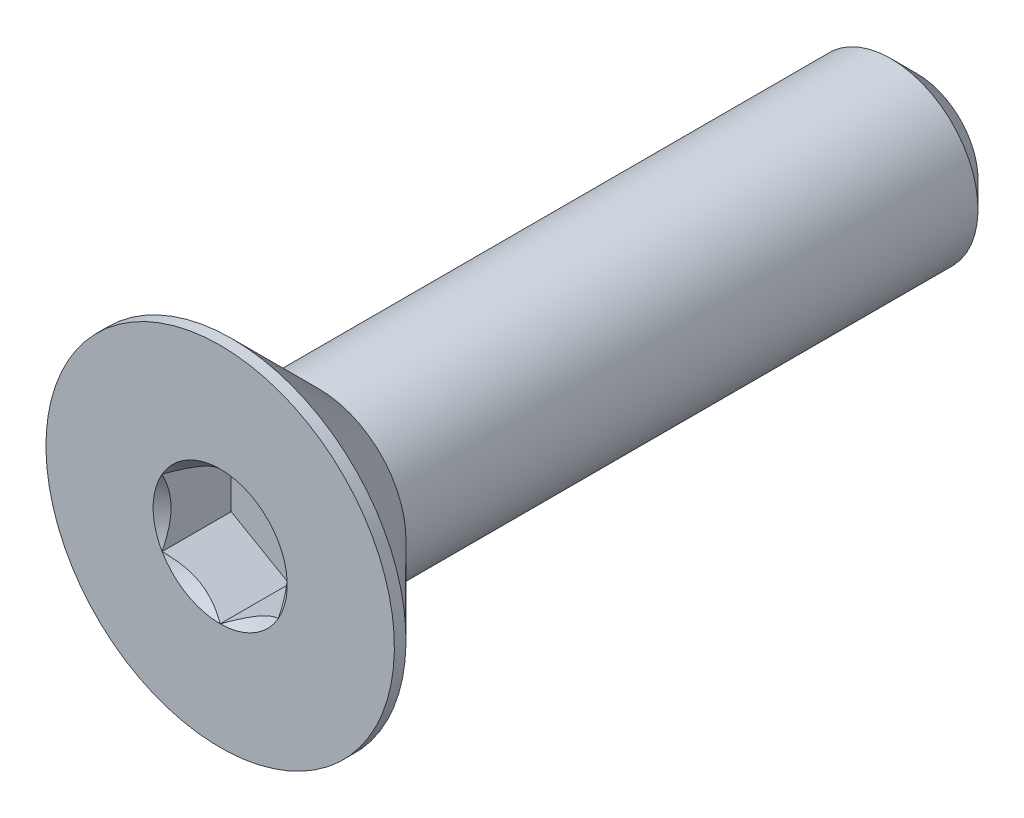
from build123d import *

# Parameters (mm, degrees)
SKETCH3_W          = 12
SKETCH3_H          = 1.5
CHAMFER1_SIZE      = 0.45
CUT_EXTRUDE1_DEPTH = 1.19


with BuildPart() as part:
    # Sketch3 → Revolve1 (revolve)
    with BuildSketch(Plane(origin=(0, 0, 0), x_dir=(0, 0, -1), z_dir=(1, 0, 0))):
        with Locations((0, 0.75)):
            Rectangle(SKETCH3_W, SKETCH3_H)
    revolve(axis=Axis((0, 0, -6), (0, 0, 1)))

    # Chamfer1
    chamfer1_edges = [part.edges().sort_by_distance(p)[0] for p in [
        (0, -1.5, -6),
    ]]
    chamfer(chamfer1_edges, length=CHAMFER1_SIZE)

    # Sketch6 → Revolve2 (revolve)
    with BuildSketch(Plane(origin=(0, 0, 0), x_dir=(0, 0, -1), z_dir=(1, 0, 0))):
        Polygon((-6, 3), (-5.8, 3), (-4.3, 1.5), (-4.3, 0), (-6, 0), align=None)
    revolve(axis=Axis((0, 0, -6), (0, 0, 1)))

    # Sketch8 → Cut-Extrude1 (cut)
    with BuildSketch(Plane.XY.offset(6)):
        Polygon((0, 1.154700538), (-1, 0.577350269), (-1, -0.577350269), (0, -1.154700538), (1, -0.577350269), (1, 0.577350269), align=None)
    extrude(amount=-CUT_EXTRUDE1_DEPTH, mode=Mode.SUBTRACT)

    # Cut-Extrude2 cone 1 section (through the dimple's axis) → Cut-Extrude2 (revolve, cut)
    with BuildSketch(Plane(origin=(0, 0, 6), x_dir=(0, -1, 0), z_dir=(1, 0, 0))):
        Polygon((0, 0), (1.154700538, 0), (0, 1.154700538), align=None)
    revolve(axis=Axis((0, 0, 6), (0, 0, -1)), mode=Mode.SUBTRACT)


solid = part.part
